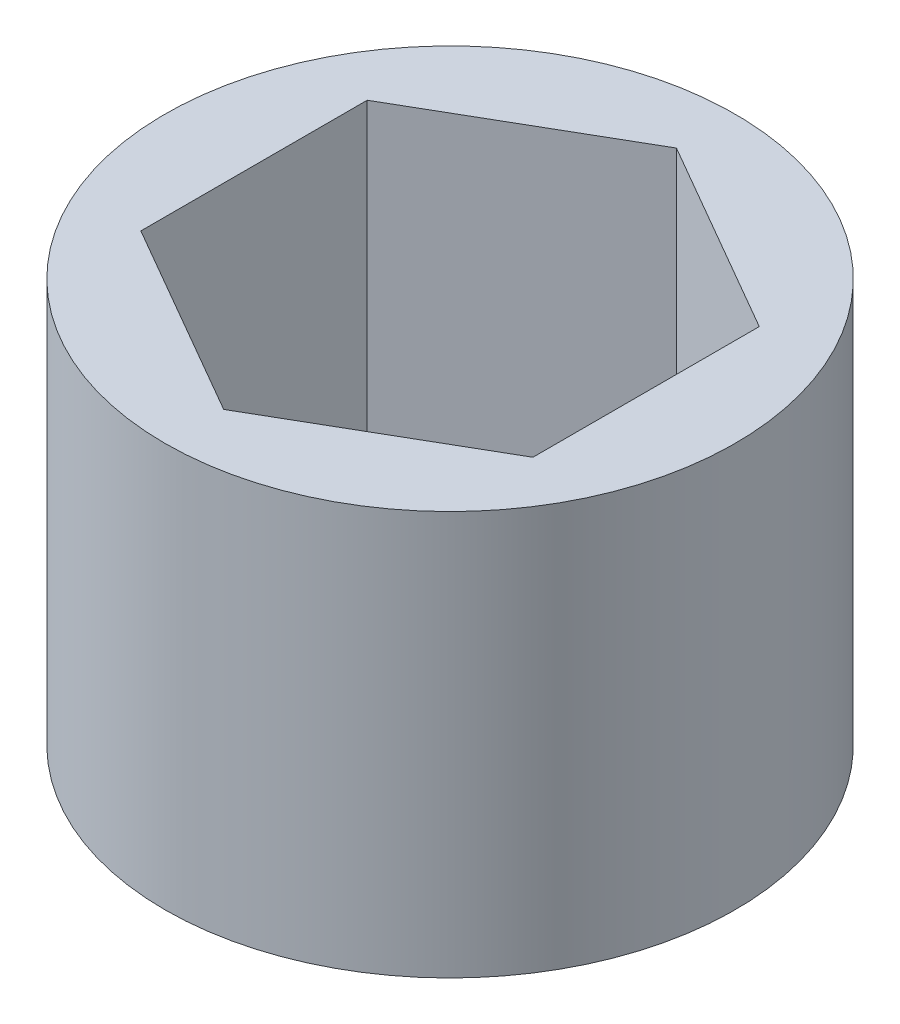
from build123d import *

# Parameters (mm, degrees)
SKETCH1_R           = 9.525
BOSS_EXTRUDE1_DEPTH = 13.49375


with BuildPart() as part:
    # Sketch1 → Boss-Extrude1 (new body)
    with BuildSketch(Plane(origin=(0, 0, 0), x_dir=(1, 0, 0), z_dir=(0, 1, 0))):
        Circle(SKETCH1_R)
        Polygon((0, 7.561484307), (-6.5484375, 3.780742153), (-6.5484375, -3.780742153), (0, -7.561484307), (6.5484375, -3.780742153), (6.5484375, 3.780742153), align=None, mode=Mode.SUBTRACT)
    extrude(amount=BOSS_EXTRUDE1_DEPTH)


solid = part.part
